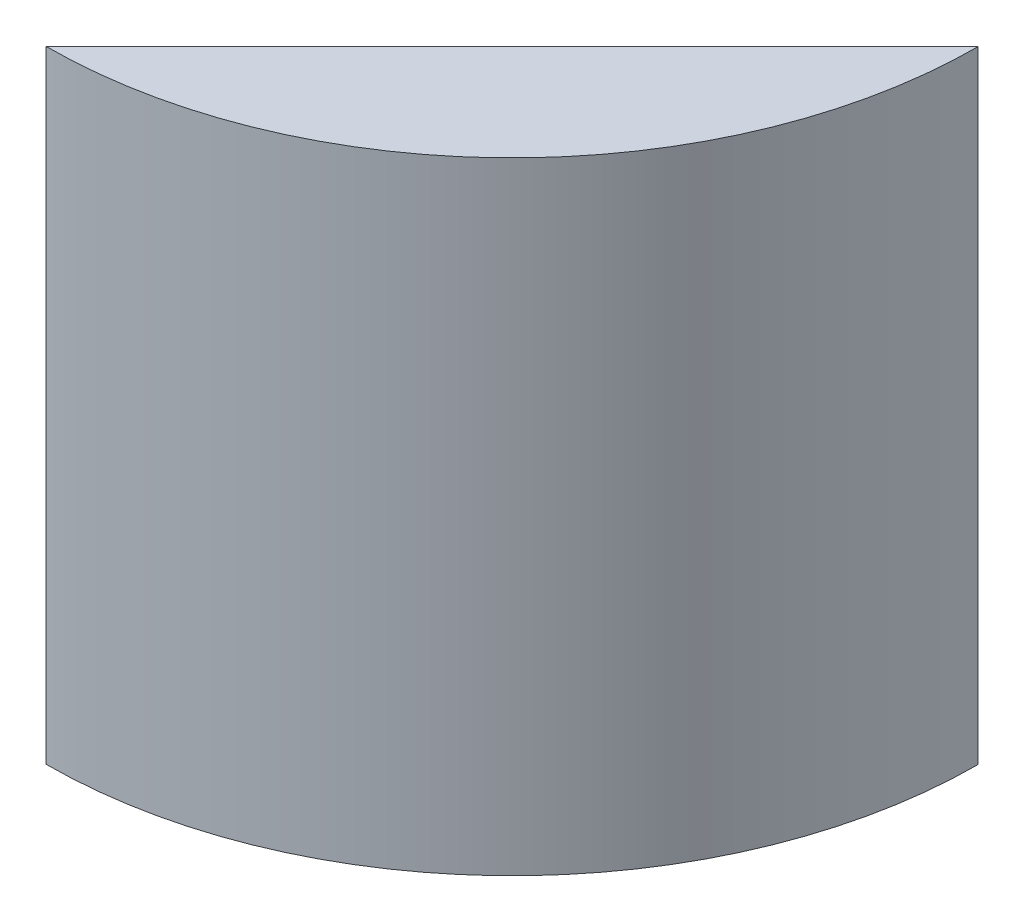
from build123d import *

# Parameters (mm, degrees)
SKETCH1_R           = 85.725
BOSS_EXTRUDE1_DEPTH = 114.3
CUT_EXTRUDE1_DEPTH  = 152.4
SKETCH3_R           = 2.778125
CUT_EXTRUDE2_DEPTH  = 12.7
SKETCH4_R           = 6.985
CUT_EXTRUDE3_DEPTH  = 6.096


with BuildPart() as part:
    # Sketch1 → Boss-Extrude1 (new body)
    with BuildSketch(Plane(origin=(0, 0, 0), x_dir=(1, 0, 0), z_dir=(0, 1, 0))):
        Circle(SKETCH1_R)
    extrude(amount=BOSS_EXTRUDE1_DEPTH)

    # Sketch2 → Cut-Extrude1 (cut)
    with BuildSketch(Plane(origin=(0, 114.3, 0), x_dir=(1, 0, 0), z_dir=(0, 1, 0))):
        Polygon((85.724933621, -0.10668), (0, -85.725), (-45.627504124, -96.719379999), (-137.428949547, 46.173941299), (19.12530113, 101.910533163), (109.833872203, 30.600481808), align=None)
    extrude(amount=-CUT_EXTRUDE1_DEPTH, mode=Mode.SUBTRACT)

    # Sketch3 → Cut-Extrude2 (cut)
    with BuildSketch(Plane(origin=(42.862466811, 0, 42.91584), x_dir=(-0.707546622, 0, 0.706666667), z_dir=(-0.706666667, 0, -0.707546622))):
        with Locations((-37.719, 87.122)):
            Circle(SKETCH3_R)
        with Locations((-14.859, 87.122)):
            Circle(SKETCH3_R)
        with Locations((-37.719, 29.21)):
            Circle(SKETCH3_R)
        with Locations((-14.859, 29.21)):
            Circle(SKETCH3_R)
        with Locations((6.643736743, 73.636006083)):
            Circle(SKETCH3_R)
        with Locations((26.963736743, 73.636006083)):
            Circle(SKETCH3_R)
    extrude(amount=-CUT_EXTRUDE2_DEPTH, mode=Mode.SUBTRACT)

    # Sketch4 → Cut-Extrude3 (cut)
    with BuildSketch(Plane(origin=(0, 0, 0), x_dir=(-1, 0, 0), z_dir=(0, -1, 0))):
        with Locations((-51.720733405, -51.785137083)):
            Circle(SKETCH4_R)
    extrude(amount=-CUT_EXTRUDE3_DEPTH, mode=Mode.SUBTRACT)


solid = part.part
